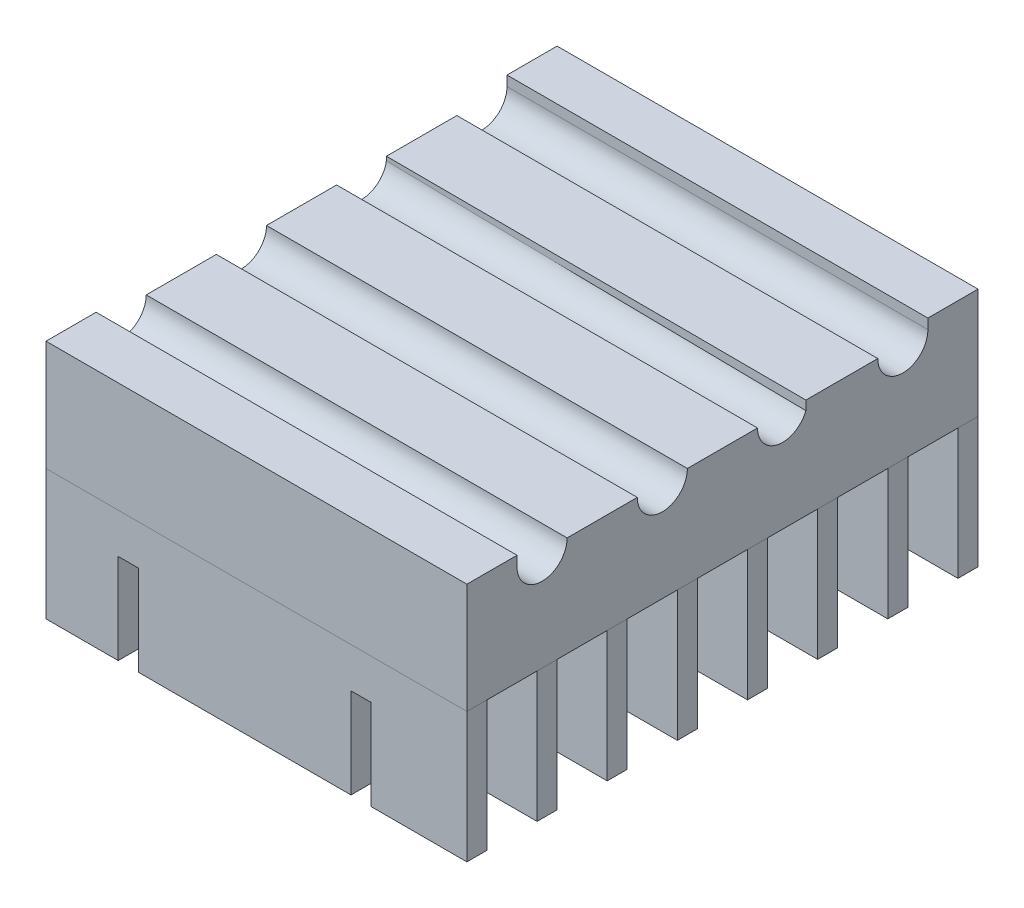
from build123d import *

# Parameters (mm, degrees)
SKETCH2_W             = 42
SKETCH2_H             = 7
BOSS_EXTRUDE1_DEPTH   = 10
BOSS_EXTRUDE1_2_DEPTH = 10
BOSS_EXTRUDE1_3_DEPTH = 10
BOSS_EXTRUDE1_4_DEPTH = 10
BOSS_EXTRUDE2_DEPTH   = 42
SKETCH4_W             = 2
SKETCH4_H             = 13
BOSS_EXTRUDE3_DEPTH   = 42
LPATTERN1_COUNT       = 8
LPATTERN1_PITCH       = 7
CUT_EXTRUDE1_DEPTH    = 51


with BuildPart() as part:
    # Sketch2 → Boss-Extrude1 (new body)
    with BuildSketch(Plane(origin=(0, 0, 0), x_dir=(1, 0, 0), z_dir=(0, 1, 0))):
        with Locations((1.180250214, -1.876958583)):
            Rectangle(SKETCH2_W, SKETCH2_H)
    extrude(amount=BOSS_EXTRUDE1_DEPTH)



with BuildPart() as body_2:
    # Sketch2 → Boss-Extrude1 2 (new body)
    with BuildSketch(Plane(origin=(0, 0, 0), x_dir=(1, 0, 0), z_dir=(0, 1, 0))):
        with BuildLine():
            Line((-28.819749786, 6.623041417), (-28.802598773, 6.622982585))
            ThreePointArc((-28.802598773, 6.622982585), (-28.811174229, 6.623026709), (-28.819749786, 6.623041417))
        make_face()
    extrude(amount=BOSS_EXTRUDE1_2_DEPTH)


with BuildPart() as body_3:
    # Sketch2 → Boss-Extrude1 3 (new body)
    with BuildSketch(Plane(origin=(0, 0, 0), x_dir=(1, 0, 0), z_dir=(0, 1, 0))):
        Polygon((-19.819749786, 6.592169231), (22.180250214, 6.448099027), (22.180250214, 13.623041417), (-19.819749786, 13.623041417), align=None)
    extrude(amount=BOSS_EXTRUDE1_3_DEPTH)


with BuildPart() as body_4:
    # Sketch2 → Boss-Extrude1 4 (new body)
    with BuildSketch(Plane(origin=(0, 0, 0), x_dir=(1, 0, 0), z_dir=(0, 1, 0))):
        with Locations((1.180250214, -13.876958583)):
            Rectangle(SKETCH2_W, SKETCH2_H)
    extrude(amount=BOSS_EXTRUDE1_4_DEPTH)


with BuildPart() as part_1:
    add(part.part)

    add(body_3.part)  # Boss-Extrude2 merges body 3

    add(body_4.part)  # Boss-Extrude2 merges body 4
    # Sketch3 → Boss-Extrude2 (add)
    with BuildSketch(Plane(origin=(22.180250214, 0, 0), x_dir=(0, 0, -1), z_dir=(1, 0, 0))):
        with BuildLine():
            Line((-17.376958583, 10), (-10.376958583, 10))
            ThreePointArc((-10.376958583, 10), (-7.876958583, 7.5), (-5.376958583, 10))
            Line((-5.376958583, 10), (1.623041417, 10))
            ThreePointArc((1.623041417, 10), (4.123041417, 7.5), (6.623041417, 10))
            Line((6.623041417, 10), (13.623041417, 10))
            ThreePointArc((13.623041417, 10), (16.123041417, 7.5), (18.623041417, 10))
            Line((18.623041417, 10), (18.623041417, 11))
            Line((18.623041417, 11), (23.623041417, 11))
            Line((23.623041417, 11), (23.623041417, 0))
            Line((23.623041417, 0), (-27.376958583, 0))
            Line((-27.376958583, 0), (-27.376958583, 11))
            Line((-27.376958583, 11), (-22.376958583, 11))
            Line((-22.376958583, 11), (-22.376958583, 10))
            ThreePointArc((-22.376958583, 10), (-19.876958583, 7.5), (-17.376958583, 10))
        make_face()
    extrude(amount=-BOSS_EXTRUDE2_DEPTH)


with BuildPart() as body_3_2:
    # Sketch4 → Boss-Extrude3 (new body)
    with BuildSketch(Plane(origin=(22.180250214, 0, 0), x_dir=(0, 0, -1), z_dir=(1, 0, 0))):
        with Locations((22.623041417, -6.5)):
            Rectangle(SKETCH4_W, SKETCH4_H)
    boss_extrude3 = extrude(amount=-BOSS_EXTRUDE3_DEPTH)


with BuildPart() as lpattern1_1:
    # LPattern1: pattern copy
    add(boss_extrude3.moved(Location(Vector(0, 0, 1) * (1 * LPATTERN1_PITCH))))


with BuildPart() as lpattern1_2:
    # LPattern1: pattern copy
    add(boss_extrude3.moved(Location(Vector(0, 0, 1) * (2 * LPATTERN1_PITCH))))


with BuildPart() as lpattern1_3:
    # LPattern1: pattern copy
    add(boss_extrude3.moved(Location(Vector(0, 0, 1) * (3 * LPATTERN1_PITCH))))


with BuildPart() as lpattern1_4:
    # LPattern1: pattern copy
    add(boss_extrude3.moved(Location(Vector(0, 0, 1) * (4 * LPATTERN1_PITCH))))


with BuildPart() as lpattern1_5:
    # LPattern1: pattern copy
    add(boss_extrude3.moved(Location(Vector(0, 0, 1) * (5 * LPATTERN1_PITCH))))


with BuildPart() as lpattern1_6:
    # LPattern1: pattern copy
    add(boss_extrude3.moved(Location(Vector(0, 0, 1) * (6 * LPATTERN1_PITCH))))


with BuildPart() as lpattern1_7:
    # LPattern1: pattern copy
    add(boss_extrude3.moved(Location(Vector(0, 0, 1) * (7 * LPATTERN1_PITCH))))


with BuildPart() as cut_extrude1_tool:
    # Sketch5 → Cut-Extrude1 (new body)
    with BuildSketch(Plane.XY.offset(27.376958583)):
        Polygon((12.613836154, -13), (12.613836154, -4), (10.613836154, -4), (10.613836154, -14.372038729), (12.613836154, -14.372038729), align=None)
        Polygon((-12.613836154, -14.372038729), (-12.613836154, -13), (-12.613836154, -4), (-10.613836154, -4), (-10.613836154, -14.372038729), align=None)
    extrude(amount=-CUT_EXTRUDE1_DEPTH)


with BuildPart() as body_3_2_1:
    add(body_3_2.part)

    # Cut-Extrude1: cut by cut_extrude1_tool
    add(cut_extrude1_tool.part, mode=Mode.SUBTRACT)


with BuildPart() as lpattern1_1_1:
    add(lpattern1_1.part)

    # Cut-Extrude1: cut by cut_extrude1_tool
    add(cut_extrude1_tool.part, mode=Mode.SUBTRACT)


with BuildPart() as lpattern1_2_1:
    add(lpattern1_2.part)

    # Cut-Extrude1: cut by cut_extrude1_tool
    add(cut_extrude1_tool.part, mode=Mode.SUBTRACT)


with BuildPart() as lpattern1_3_1:
    add(lpattern1_3.part)

    # Cut-Extrude1: cut by cut_extrude1_tool
    add(cut_extrude1_tool.part, mode=Mode.SUBTRACT)


with BuildPart() as lpattern1_4_1:
    add(lpattern1_4.part)

    # Cut-Extrude1: cut by cut_extrude1_tool
    add(cut_extrude1_tool.part, mode=Mode.SUBTRACT)


with BuildPart() as lpattern1_5_1:
    add(lpattern1_5.part)

    # Cut-Extrude1: cut by cut_extrude1_tool
    add(cut_extrude1_tool.part, mode=Mode.SUBTRACT)


with BuildPart() as lpattern1_6_1:
    add(lpattern1_6.part)

    # Cut-Extrude1: cut by cut_extrude1_tool
    add(cut_extrude1_tool.part, mode=Mode.SUBTRACT)


with BuildPart() as lpattern1_7_1:
    add(lpattern1_7.part)

    # Cut-Extrude1: cut by cut_extrude1_tool
    add(cut_extrude1_tool.part, mode=Mode.SUBTRACT)


solid = Compound([body_2.part, part_1.part, body_3_2_1.part, lpattern1_1_1.part, lpattern1_2_1.part, lpattern1_3_1.part, lpattern1_4_1.part, lpattern1_5_1.part, lpattern1_6_1.part, lpattern1_7_1.part])
